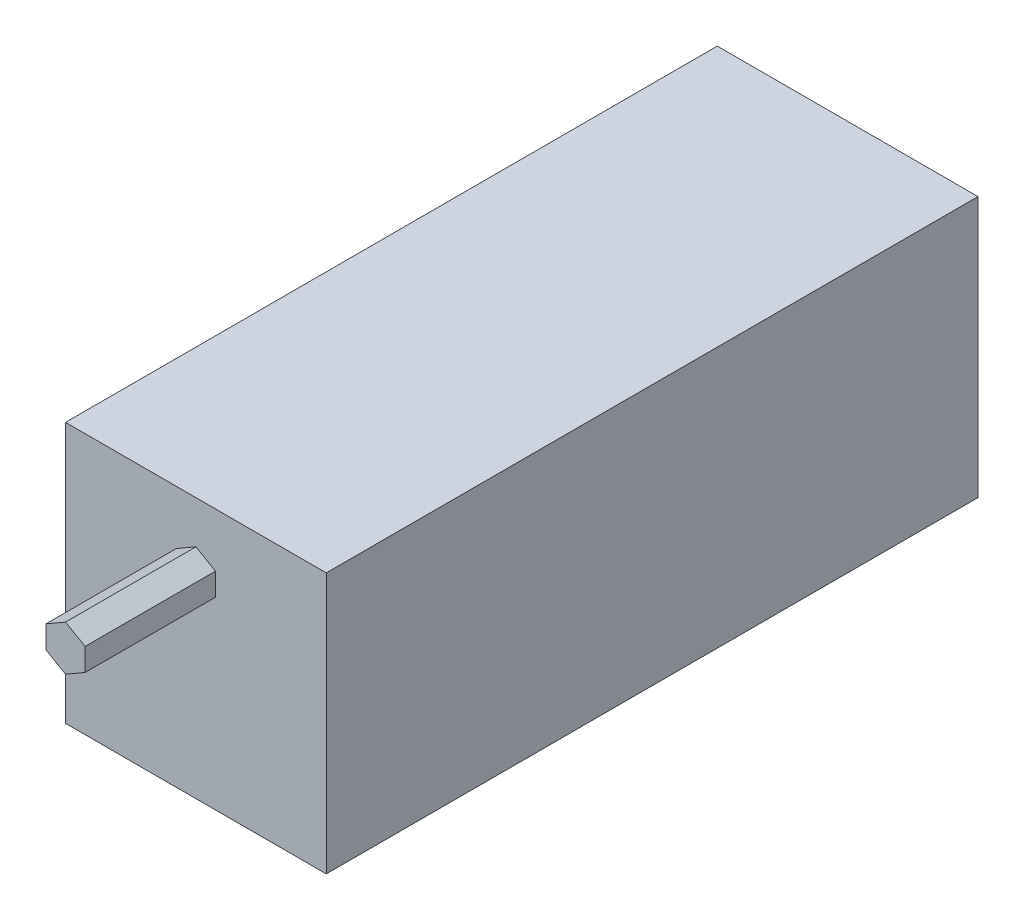
from build123d import *

# Parameters (mm, degrees)
ESQUISSE1_W        = 40
ESQUISSE1_H        = 100
BOSS_EXTRU_1_DEPTH = 40
BOSS_EXTRU_2_DEPTH = 20


with BuildPart() as part:
    # Esquisse1 → Boss.-Extru.1 (new body)
    with BuildSketch(Plane(origin=(0, 0, 0), x_dir=(1, 0, 0), z_dir=(0, 1, 0))):
        with Locations((20, 50)):
            Rectangle(ESQUISSE1_W, ESQUISSE1_H)
    extrude(amount=BOSS_EXTRU_1_DEPTH)

    # Esquisse2 → Boss.-Extru.2 (add)
    with BuildSketch(Plane.XY):
        Polygon((23, 28.267949192), (23, 31.732050808), (20, 33.464101615), (17, 31.732050808), (17, 28.267949192), (20, 26.535898385), align=None)
    extrude(amount=BOSS_EXTRU_2_DEPTH)


solid = part.part
